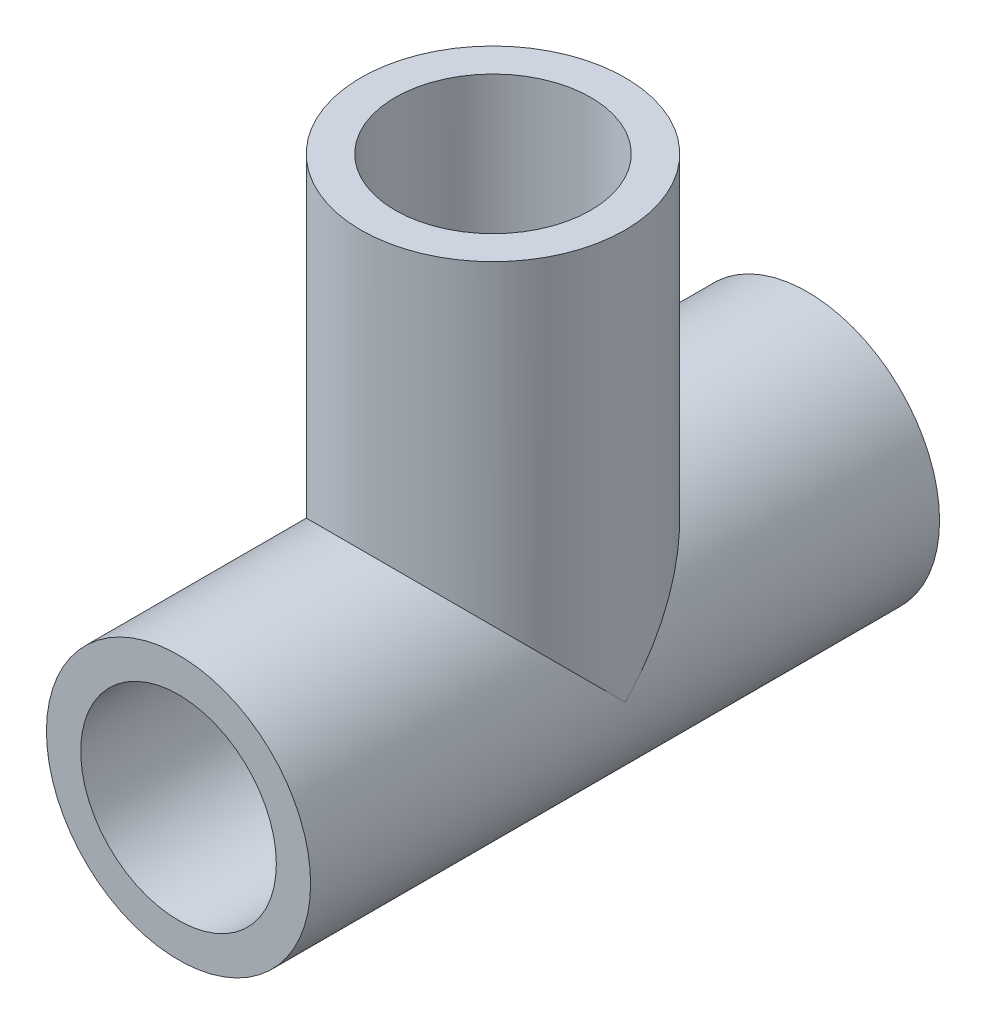
from build123d import *

# Parameters (mm, degrees)
SKETCH1_R           = 10.668
SKETCH1_R_2         = 7.8994
BOSS_EXTRUDE1_DEPTH = 50.8
SKETCH2_R           = 10.668
SKETCH2_R_2         = 7.8994
BOSS_EXTRUDE2_DEPTH = 33.02
SKETCH3_R           = 7.8994
CUT_EXTRUDE1_DEPTH  = 51.8000001
CUT_EXTRUDE2_REACH  = 45.688
SKETCH4_R           = 7.8994


with BuildPart() as part:
    # Sketch1 → Boss-Extrude1 (new body)
    with BuildSketch(Plane.XY):
        Circle(SKETCH1_R)
        Circle(SKETCH1_R_2, mode=Mode.SUBTRACT)
    extrude(amount=BOSS_EXTRUDE1_DEPTH)

    # Sketch2 → Boss-Extrude2 (add)
    with BuildSketch(Plane(origin=(0, 0, 0), x_dir=(1, 0, 0), z_dir=(0, 1, 0))):
        with Locations((0, -25.4)):
            Circle(SKETCH2_R)
        with Locations((0, -25.4)):
            Circle(SKETCH2_R_2, mode=Mode.SUBTRACT)
    extrude(amount=BOSS_EXTRUDE2_DEPTH)

    # Sketch3 → Cut-Extrude1 (cut, through all)
    with BuildSketch(Plane.XY.offset(50.8)):
        Circle(SKETCH3_R)
    extrude(amount=-CUT_EXTRUDE1_DEPTH, mode=Mode.SUBTRACT)

    # Sketch4 → Cut-Extrude2 (cut, up to next)
    with BuildSketch(Plane(origin=(0, 33.02, 0), x_dir=(1, 0, 0), z_dir=(0, 1, 0)), mode=Mode.PRIVATE) as cut_extrude2_sk1:
        with Locations((0, -25.4)):
            Circle(SKETCH4_R)
    cut_extrude2_tool1 = extrude(cut_extrude2_sk1.sketch, amount=-CUT_EXTRUDE2_REACH, mode=Mode.PRIVATE) & part.part
    add(cut_extrude2_tool1.solids().sort_by_distance((0, 33.02, 25.4))[0], mode=Mode.SUBTRACT)


solid = part.part
